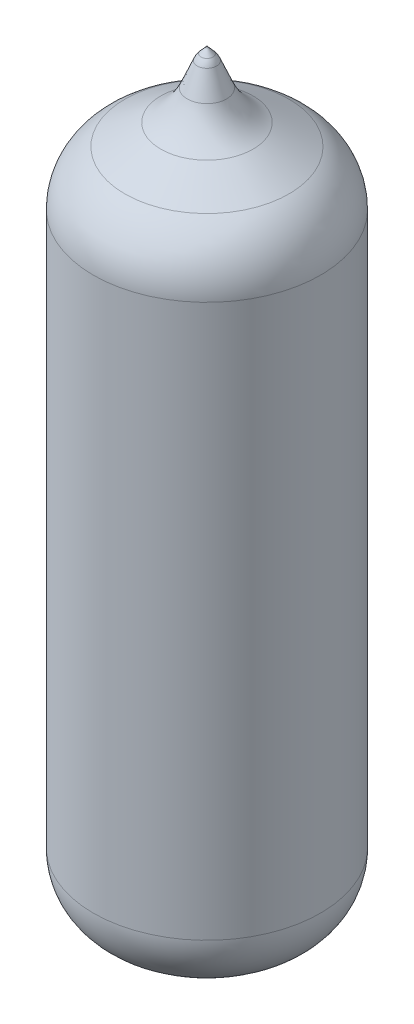
from build123d import *


with BuildPart() as part:
    # Esquisse1 → Révolution1 (revolve)
    with BuildSketch(Plane.XY):
        with BuildLine():
            Line((-3.902413526, 31.860615398), (-2.193843177, 32.849176927))
            ThreePointArc((-2.193843177, 32.849176927), (-1.444814591, 33.46318111), (-0.930447552, 34.283834209))
            Line((-0.930447552, 34.283834209), (-0.459450443, 35.40488518))
            ThreePointArc((-0.459450443, 35.40488518), (-0.382581088, 35.552204227), (-0.282377912, 35.684760339))
            Line((-0.282377912, 35.684760339), (0, 36))
            Line((0, 36), (0, 0))
            Line((0, 0), (-2.4, 0))
            ThreePointArc((-2.4, 0), (-4.521320344, 0.878679656), (-5.4, 3))
            Line((-5.4, 3), (-5.4, 29.263934132))
            ThreePointArc((-5.4, 29.263934132), (-4.998772843, 30.762726883), (-3.902413526, 31.860615398))
        make_face()
    revolve(axis=Axis((0, 36, 0), (0, -1, 0)))


solid = part.part
